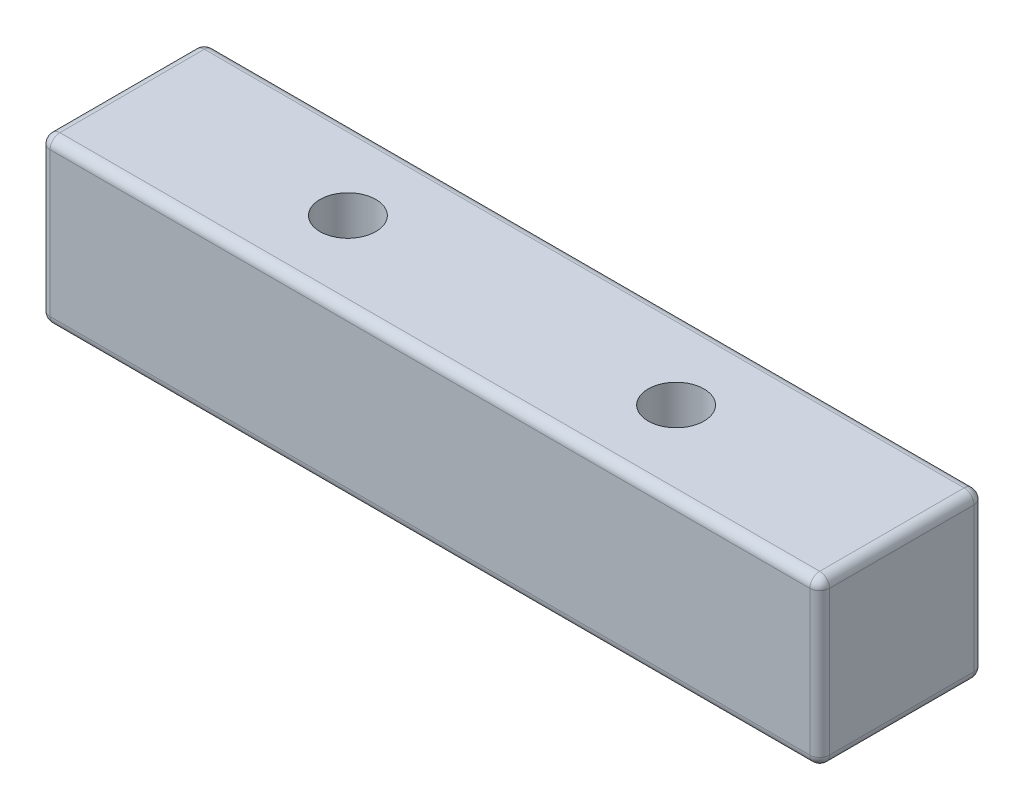
from build123d import *

# Parameters (mm, degrees)
SKETCH1_W           = 60.325
SKETCH1_H           = 12.7
SKETCH1_R           = 2.159
BOSS_EXTRUDE1_DEPTH = 12.7
SKETCH5_R           = 3.556
CUT_EXTRUDE1_DEPTH  = 3.81
FILLET1_R           = 0.762


with BuildPart() as part:
    # Sketch1 → Boss-Extrude1 (new body)
    with BuildSketch(Plane(origin=(0, 0, 0), x_dir=(1, 0, 0), z_dir=(0, 1, 0))):
        with Locations((30.1625, 6.35)):
            Rectangle(SKETCH1_W, SKETCH1_H)
        with Locations((17.4625, 6.35)):
            Circle(SKETCH1_R, mode=Mode.SUBTRACT)
        with Locations((42.8625, 6.35)):
            Circle(SKETCH1_R, mode=Mode.SUBTRACT)
    extrude(amount=BOSS_EXTRUDE1_DEPTH)

    # Sketch5 → Cut-Extrude1 (cut)
    with BuildSketch(Plane.XZ):
        with Locations((42.8625, -6.35)):
            Circle(SKETCH5_R)
        with Locations((17.4625, -6.35)):
            Circle(SKETCH5_R)
    extrude(amount=-CUT_EXTRUDE1_DEPTH, mode=Mode.SUBTRACT)

    # Fillet1
    fillet1_edges = [part.edges().sort_by_distance(p)[0] for p in [
        (60.325, 12.7, -6.35),
        (30.1625, 12.7, -12.7),
        (39.3065, 0, -6.35),
        (13.9065, 0, -6.35),
        (0, 12.7, -6.35),
        (30.1625, 0, -12.7),
        (60.325, 0, -6.35),
        (30.1625, 0, 0),
        (0, 0, -6.35),
        (30.1625, 12.7, 0),
        (0, 6.35, -12.7),
        (60.325, 6.35, -12.7),
        (60.325, 6.35, 0),
        (0, 6.35, 0),
    ]]
    fillet(fillet1_edges, radius=FILLET1_R)


solid = part.part
